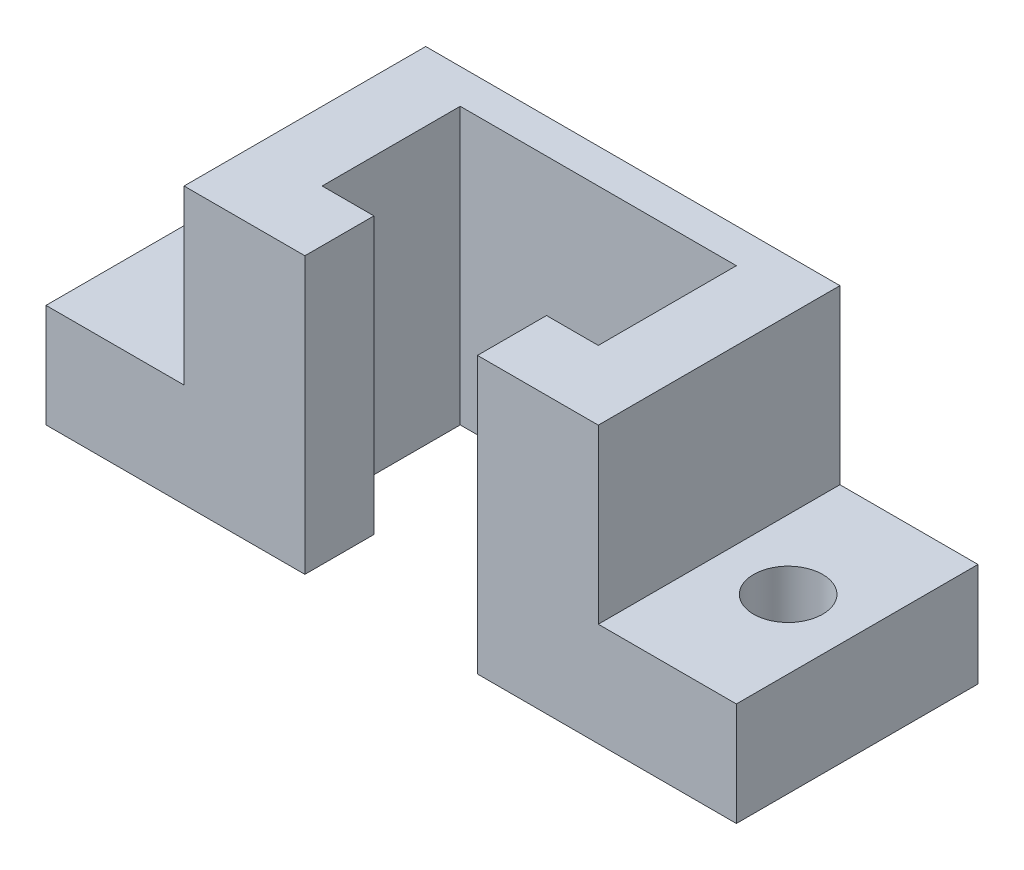
from build123d import *

# Parameters (mm, degrees)
ESBO_O1_W                = 60
ESBO_O1_H                = 40
RESSALTO_EXTRUS_O1_DEPTH = 35
ESBO_O3_W                = 40
ESBO_O3_H                = 20
CORTE_EXTRUS_O2_DEPTH    = 80
ESBO_O4_W                = 25
ESBO_O4_H                = 10
CORTE_EXTRUS_O3_DEPTH    = 80
ESBO_O5_W                = 35
ESBO_O5_H                = 15
RESSALTO_EXTRUS_O2_DEPTH = 20
ESBO_O6_W                = 35
ESBO_O6_H                = 15
RESSALTO_EXTRUS_O3_DEPTH = 20
ESBO_O7_W                = 60
ESBO_O7_H                = 35
RESSALTO_EXTRUS_O4_DEPTH = 10
ESBO_O8_R                = 5
CORTE_EXTRUS_O4_DEPTH    = 51
ESBO_O9_W                = 60
ESBO_O9_H                = 10.026146623
CORTE_EXTRUS_O5_DEPTH    = 36


with BuildPart() as part:
    # Esboço1 → Ressalto-extrusão1 (new body)
    with BuildSketch(Plane.XY):
        Rectangle(ESBO_O1_W, ESBO_O1_H)
    extrude(amount=RESSALTO_EXTRUS_O1_DEPTH)

    # Esboço3 → Corte-extrusão2 (cut)
    with BuildSketch(Plane(origin=(0, 20, 0), x_dir=(1, 0, 0), z_dir=(0, 1, 0))):
        with Locations((0, -15)):
            Rectangle(ESBO_O3_W, ESBO_O3_H)
    extrude(amount=-CORTE_EXTRUS_O2_DEPTH, mode=Mode.SUBTRACT)

    # Esboço4 → Corte-extrusão3 (cut)
    with BuildSketch(Plane(origin=(0, 20, 0), x_dir=(1, 0, 0), z_dir=(0, 1, 0))):
        with Locations((0, -30)):
            Rectangle(ESBO_O4_W, ESBO_O4_H)
    extrude(amount=-CORTE_EXTRUS_O3_DEPTH, mode=Mode.SUBTRACT)

    # Esboço5 → Ressalto-extrusão2 (add)
    with BuildSketch(Plane(origin=(30, 0, 0), x_dir=(0, 0, -1), z_dir=(1, 0, 0))):
        with Locations((-17.5, -12.5)):
            Rectangle(ESBO_O5_W, ESBO_O5_H)
    extrude(amount=RESSALTO_EXTRUS_O2_DEPTH)

    # Esboço6 → Ressalto-extrusão3 (add)
    with BuildSketch(Plane.ZY.offset(30)):
        with Locations((17.5, -12.5)):
            Rectangle(ESBO_O6_W, ESBO_O6_H)
    extrude(amount=RESSALTO_EXTRUS_O3_DEPTH)

    # Esboço7 → Ressalto-extrusão4 (add)
    with BuildSketch(Plane(origin=(0, 20, 0), x_dir=(1, 0, 0), z_dir=(0, 1, 0))):
        with Locations((0, -17.5)):
            Rectangle(ESBO_O7_W, ESBO_O7_H)
    extrude(amount=RESSALTO_EXTRUS_O4_DEPTH)

    # Esboço8 → Corte-extrusão4 (cut, through all)
    with BuildSketch(Plane.XZ.offset(20)):
        with Locations((40, 17.5)):
            Circle(ESBO_O8_R)
        with Locations((-40, 17.5)):
            Circle(ESBO_O8_R)
    extrude(amount=-CORTE_EXTRUS_O4_DEPTH, mode=Mode.SUBTRACT)

    # Esboço9 → Corte-extrusão5 (cut, through all)
    with BuildSketch(Plane.XY.offset(35)):
        with Locations((0, 24.986926689)):
            Rectangle(ESBO_O9_W, ESBO_O9_H)
    extrude(amount=-CORTE_EXTRUS_O5_DEPTH, mode=Mode.SUBTRACT)


solid = part.part
